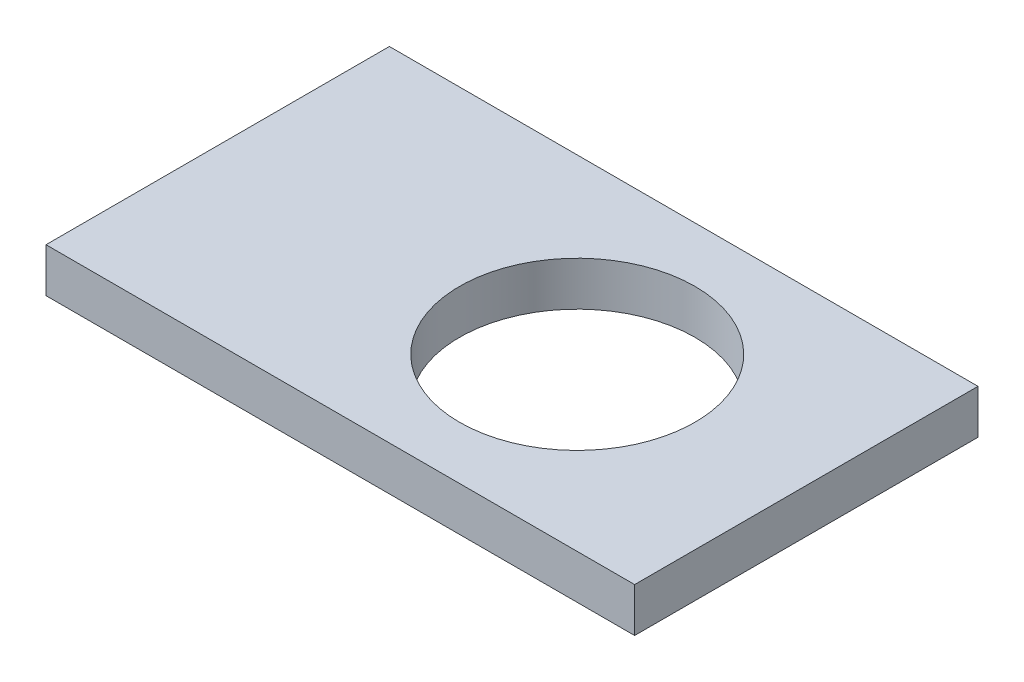
from build123d import *

# Parameters (mm, degrees)
SKETCH1_W           = 80
SKETCH1_H           = 60
SKETCH1_R           = 16
BOSS_EXTRUDE1_DEPTH = 6
SCALE1_SCALE        = 7.5
SKETCH2_W           = 741.9419144
SKETCH2_H           = 114.286704827
CUT_EXTRUDE1_DEPTH  = 46


with BuildPart() as part:
    # Sketch1 → Boss-Extrude1 (new body)
    with BuildSketch(Plane(origin=(0, 0, 0), x_dir=(1, 0, 0), z_dir=(0, 1, 0))):
        with Locations((40, 30)):
            Rectangle(SKETCH1_W, SKETCH1_H)
        with Locations((49, 23.2)):
            Circle(SKETCH1_R, mode=Mode.SUBTRACT)
    extrude(amount=BOSS_EXTRUDE1_DEPTH)


with BuildPart() as part_1:
    # Scale1: scaled about (38.188518966, 3, -31.368674559)
    add(part.part.scale(SCALE1_SCALE).moved(Location((-248.225373279, -19.5, 203.896384633))))

    # Sketch2 → Cut-Extrude1 (cut, through all)
    with BuildSketch(Plane(origin=(0, 25.5, 0), x_dir=(1, 0, 0), z_dir=(0, 1, 0))):
        with Locations((57.597106318, 203.246967778)):
            Rectangle(SKETCH2_W, SKETCH2_H)
    extrude(amount=-CUT_EXTRUDE1_DEPTH, mode=Mode.SUBTRACT)


solid = part_1.part
